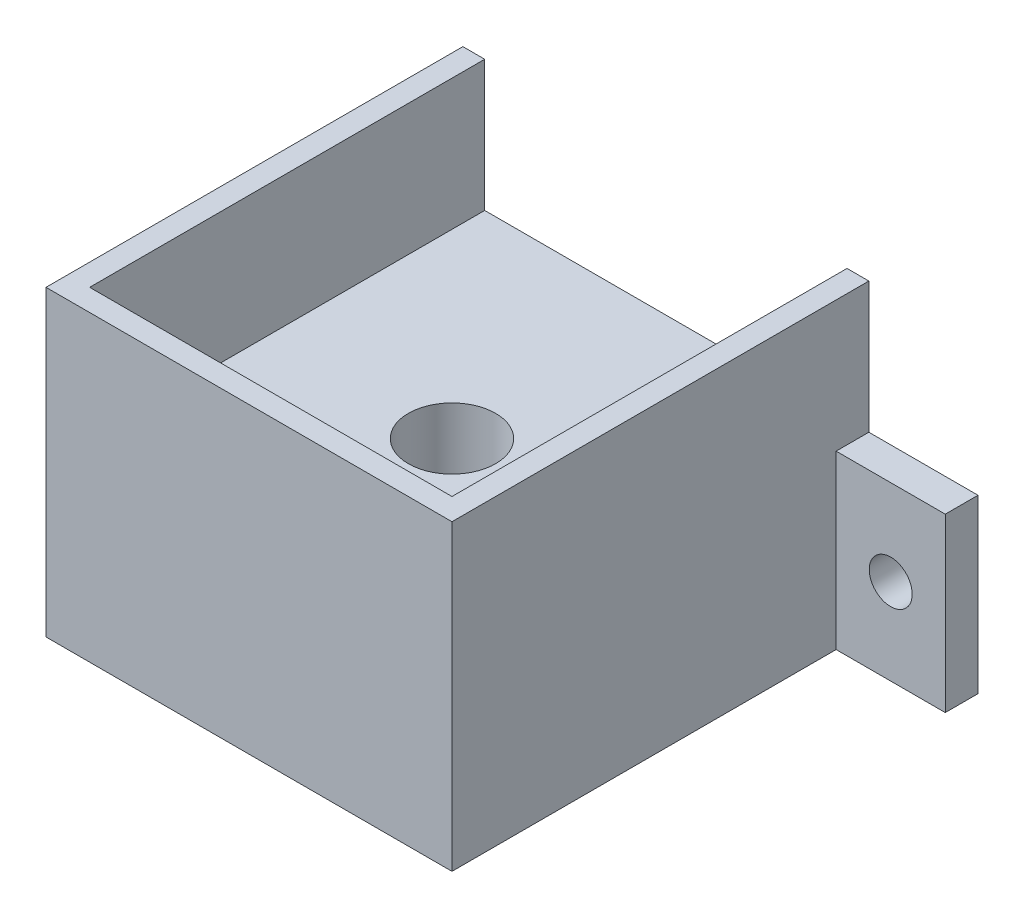
from build123d import *

# Parameters (mm, degrees)
BOSS_EXTRUDE1_DEPTH = 20
BOSS_EXTRUDE2_DEPTH = 15.24
SKETCH3_R           = 2.5
CUT_EXTRUDE1_DEPTH  = 4.81
SKETCH4_R           = 5.08
CUT_EXTRUDE2_DEPTH  = 21


with BuildPart() as part:
    # Sketch1 → Boss-Extrude1 (new body)
    with BuildSketch(Plane(origin=(0, 0, 0), x_dir=(1, 0, 0), z_dir=(0, 1, 0))):
        Polygon((-23.622, -24.257), (23.622, -24.257), (23.622, 20.447), (36.322, 20.447), (36.322, 24.257), (23.622, 24.257), (-23.622, 24.257), (-36.322, 24.257), (-36.322, 20.447), (-23.622, 20.447), align=None)
    extrude(amount=BOSS_EXTRUDE1_DEPTH)

    # Sketch2 → Boss-Extrude2 (add)
    with BuildSketch(Plane(origin=(0, 20, 0), x_dir=(1, 0, 0), z_dir=(0, 1, 0))):
        Polygon((-23.622, 24.257), (-21.082, 24.257), (-21.082, -21.717), (21.082, -21.717), (21.082, 24.257), (23.622, 24.257), (23.622, -24.257), (-21.668534476, -24.257), (-23.622, -24.257), align=None)
    extrude(amount=BOSS_EXTRUDE2_DEPTH)

    # Sketch3 → Cut-Extrude1 (cut, through all)
    with BuildSketch(Plane.XY.offset(-20.447)):
        with Locations((29.972, 10)):
            Circle(SKETCH3_R)
    cut_extrude1 = extrude(amount=-CUT_EXTRUDE1_DEPTH, mode=Mode.SUBTRACT)

    # Mirror1: Cut-Extrude1 across plane
    add(cut_extrude1.mirror(Plane(origin=(0, 0, 0), x_dir=(0, 0, 1), z_dir=(1, 0, 0))), mode=Mode.SUBTRACT)

    # Sketch4 → Cut-Extrude2 (cut, through all)
    with BuildSketch(Plane(origin=(0, 20, 0), x_dir=(1, 0, 0), z_dir=(0, 1, 0))):
        with Locations((0, -0.635)):
            Circle(SKETCH4_R)
    extrude(amount=-CUT_EXTRUDE2_DEPTH, mode=Mode.SUBTRACT)


solid = part.part
